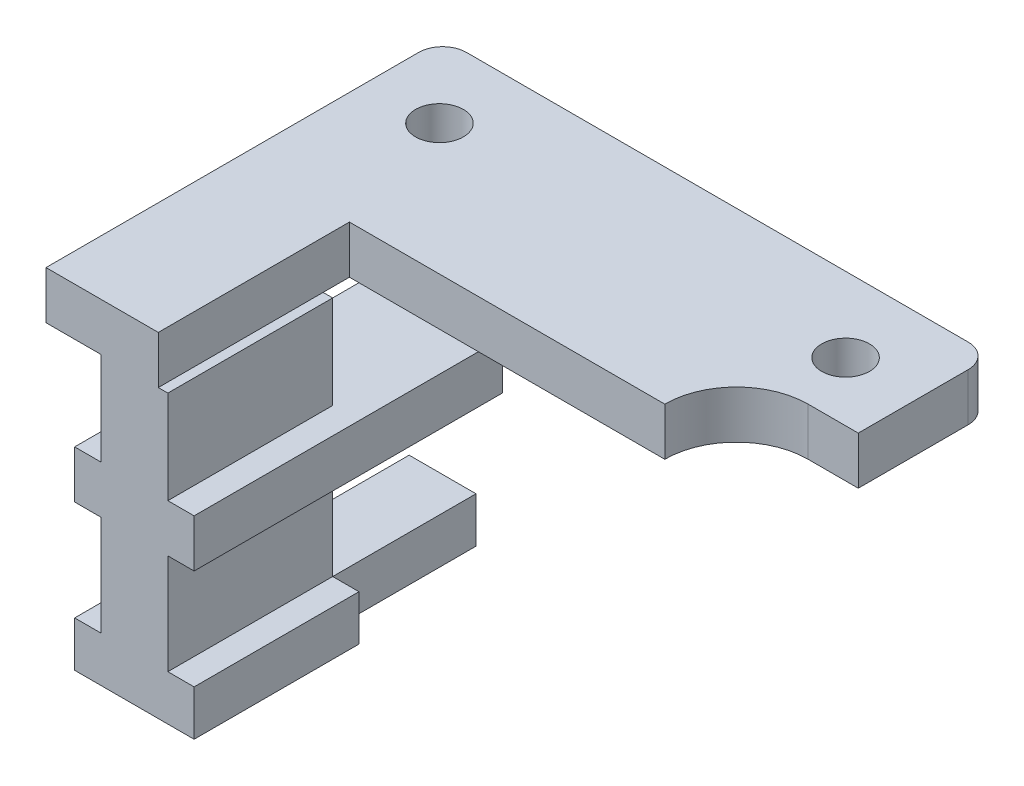
from build123d import *

# Parameters (mm, degrees)
SKETCH1_R           = 1
BOSS_EXTRUDE1_DEPTH = 2
BOSS_EXTRUDE2_START = 8
BOSS_EXTRUDE2_DEPTH = 6.9
SKETCH3_W           = 2.8
SKETCH3_H           = 1.9
SKETCH3_W_2         = 5
SKETCH3_H_2         = 2
BOSS_EXTRUDE3_DEPTH = 12.9


with BuildPart() as part:
    # Sketch1 → Boss-Extrude1 (new body)
    with BuildSketch(Plane(origin=(0, 0, 0), x_dir=(1, 0, 0), z_dir=(0, 1, 0))):
        with BuildLine():
            Line((11.7, 3), (11.7, 7.6))
            ThreePointArc((11.7, 7.6), (11.407106781, 8.307106781), (10.7, 8.6))
            Line((10.7, 8.6), (-10.3, 8.6))
            ThreePointArc((-10.3, 8.6), (-11.007106781, 8.307106781), (-11.3, 7.6))
            Line((-11.3, 7.6), (-11.3, -8))
            Line((-11.3, -8), (-6.6, -8))
            Line((-6.6, -8), (-6.6, 0))
            Line((-6.6, 0), (6.6, 0))
            ThreePointArc((6.6, 0), (7.478679656, 2.121320344), (9.6, 3))
            Line((9.6, 3), (11.7, 3))
        make_face()
        with Locations((8.7, 5.469565217)):
            Circle(SKETCH1_R, mode=Mode.SUBTRACT)
        with Locations((-8.3, 5.469565217)):
            Circle(SKETCH1_R, mode=Mode.SUBTRACT)
    extrude(amount=BOSS_EXTRUDE1_DEPTH)

    # Sketch2 → Boss-Extrude2 (add)
    with BuildSketch(Plane.XY.offset(BOSS_EXTRUDE2_START)):
        Polygon((-9, -10.1), (-9, 0), (-6.2, 0), (-6.2, -10.1), (-5.1, -10.1), (-5.1, -12), (-10.1, -12), (-10.1, -10.1), align=None)
    extrude(amount=-BOSS_EXTRUDE2_DEPTH)

    # Sketch3 → Boss-Extrude3 (add)
    with BuildSketch(Plane.XY.offset(8)):
        with Locations((-7.6, -11.05)):
            Rectangle(SKETCH3_W, SKETCH3_H)
        with Locations((-7.6, -4.9)):
            Rectangle(SKETCH3_W_2, SKETCH3_H_2)
    extrude(amount=-BOSS_EXTRUDE3_DEPTH)


solid = part.part
